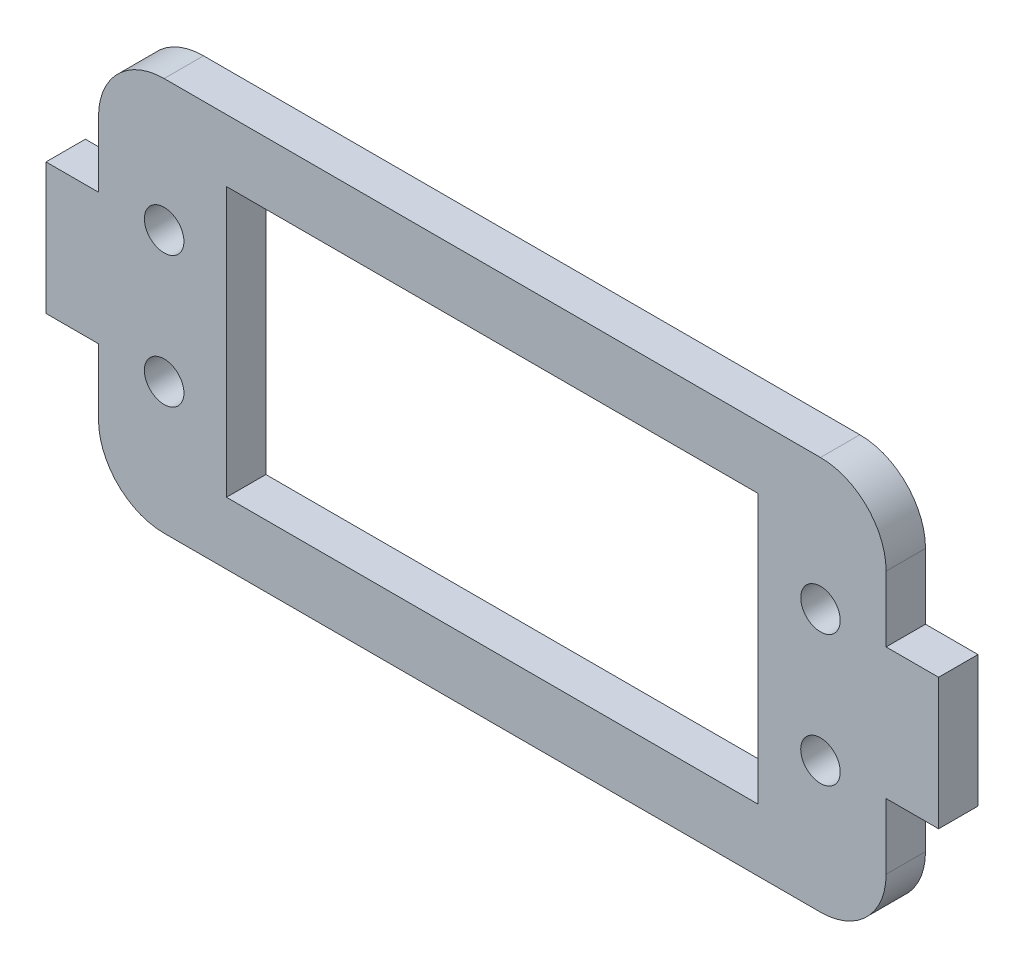
from build123d import *

# Parameters (mm, degrees)
SALIENTE_EXTRUIR1_DEPTH = 3
CORTAR_EXTRUIR1_REACH   = 5
CROQUIS2_R              = 1.505219631
CROQUIS2_W              = 40.5
CROQUIS2_H              = 20.5
REDONDEO1_R             = 5


with BuildPart() as part:
    # Croquis1 → Saliente-Extruir1 (new body)
    with BuildSketch(Plane.XY):
        Polygon((-30, -5), (-30, -15), (30, -15), (30, -5), (34, -5), (34, 5), (30, 5), (30, 15), (-30, 15), (-30, 5), (-34, 5), (-34, -5), align=None)
    extrude(amount=SALIENTE_EXTRUIR1_DEPTH)

    # Croquis2 → Cortar-Extruir1 (cut, up to next)
    with BuildSketch(Plane.XY.offset(3), mode=Mode.PRIVATE) as cortar_extruir1_sk1:
        with Locations((25, 5)):
            Circle(CROQUIS2_R)
    cortar_extruir1_tool1 = extrude(cortar_extruir1_sk1.sketch, amount=-CORTAR_EXTRUIR1_REACH, mode=Mode.PRIVATE) & part.part
    add(cortar_extruir1_tool1.solids().sort_by_distance((25, 5, 3))[0], mode=Mode.SUBTRACT)
    # Croquis2 → Cortar-Extruir1 (cut, up to next)
    with BuildSketch(Plane.XY.offset(3), mode=Mode.PRIVATE) as cortar_extruir1_sk2:
        with Locations((-25, 5)):
            Circle(CROQUIS2_R)
    cortar_extruir1_tool2 = extrude(cortar_extruir1_sk2.sketch, amount=-CORTAR_EXTRUIR1_REACH, mode=Mode.PRIVATE) & part.part
    add(cortar_extruir1_tool2.solids().sort_by_distance((-25, 5, 3))[0], mode=Mode.SUBTRACT)
    # Croquis2 → Cortar-Extruir1 (cut, up to next)
    with BuildSketch(Plane.XY.offset(3), mode=Mode.PRIVATE) as cortar_extruir1_sk3:
        with Locations((25, -5)):
            Circle(CROQUIS2_R)
    cortar_extruir1_tool3 = extrude(cortar_extruir1_sk3.sketch, amount=-CORTAR_EXTRUIR1_REACH, mode=Mode.PRIVATE) & part.part
    add(cortar_extruir1_tool3.solids().sort_by_distance((25, -5, 3))[0], mode=Mode.SUBTRACT)
    # Croquis2 → Cortar-Extruir1 (cut, up to next)
    with BuildSketch(Plane.XY.offset(3), mode=Mode.PRIVATE) as cortar_extruir1_sk4:
        with Locations((-25, -5)):
            Circle(CROQUIS2_R)
    cortar_extruir1_tool4 = extrude(cortar_extruir1_sk4.sketch, amount=-CORTAR_EXTRUIR1_REACH, mode=Mode.PRIVATE) & part.part
    add(cortar_extruir1_tool4.solids().sort_by_distance((-25, -5, 3))[0], mode=Mode.SUBTRACT)
    # Croquis2 → Cortar-Extruir1 (cut, up to next)
    with BuildSketch(Plane.XY.offset(3), mode=Mode.PRIVATE) as cortar_extruir1_sk5:
        Rectangle(CROQUIS2_W, CROQUIS2_H)
    cortar_extruir1_tool5 = extrude(cortar_extruir1_sk5.sketch, amount=-CORTAR_EXTRUIR1_REACH, mode=Mode.PRIVATE) & part.part
    add(cortar_extruir1_tool5.solids().sort_by_distance((0, 0, 3))[0], mode=Mode.SUBTRACT)

    # Redondeo1
    redondeo1_edges = [part.edges().sort_by_distance(p)[0] for p in [
        (30, -15, 1.5),
        (-30, -15, 1.5),
        (-30, 15, 1.5),
        (30, 15, 1.5),
    ]]
    fillet(redondeo1_edges, radius=REDONDEO1_R)


solid = part.part
